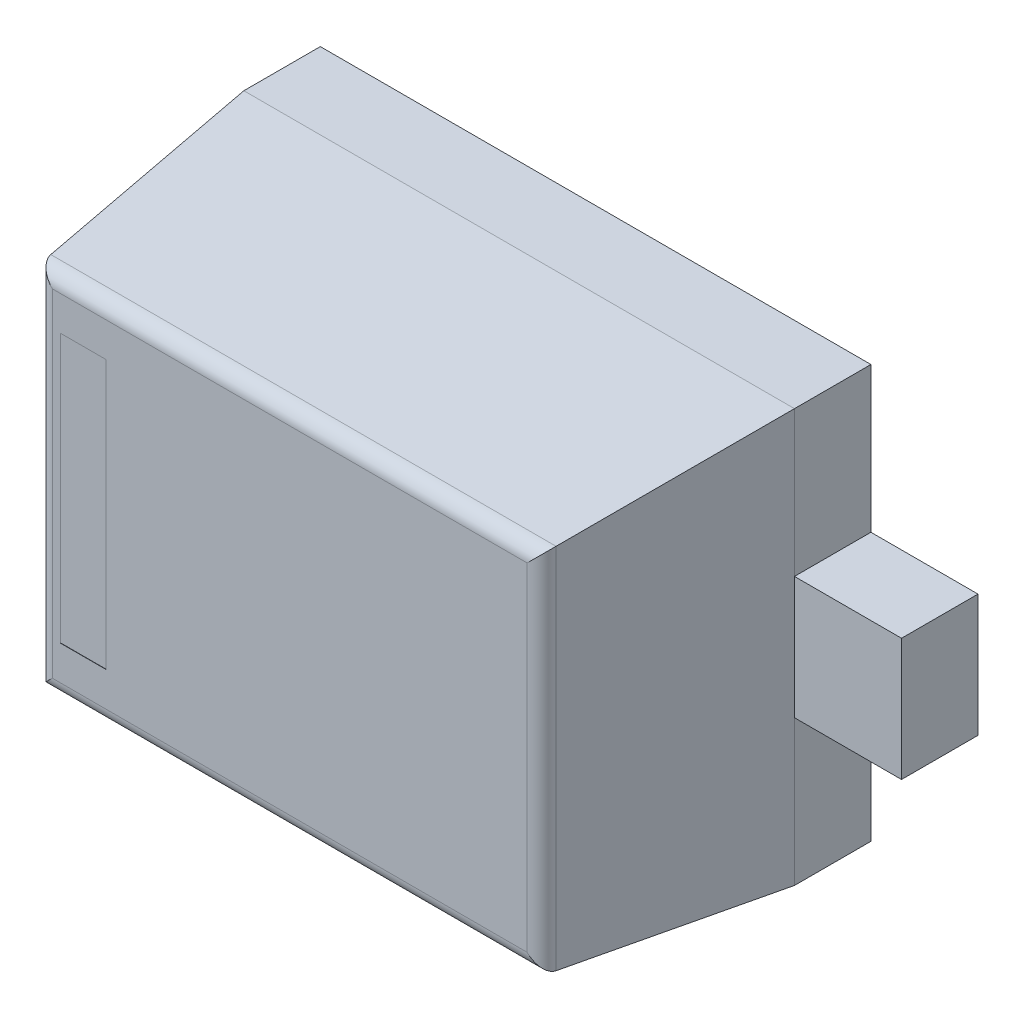
from build123d import *

# Parameters (mm, degrees)
SKBODY_W              = 1.8
SKBODY_H              = 1.35
BOSS_BODY_DEPTH       = 1
CHAMFER1_SIZE         = 0.75
CHAMFER1_SIZE2        = 0.078828176
CHAMFER1_PART_2_SIZE  = 0.75
CHAMFER1_PART_2_SIZE2 = 0.078828176
CHAMFER1_PART_3_SIZE  = 0.75
CHAMFER1_PART_3_SIZE2 = 0.078828176
CHAMFER1_PART_4_SIZE  = 0.75
CHAMFER1_PART_4_SIZE2 = 0.078828176
FILLET1_R             = 0.05
SKPOLARITY_W          = 0.15
SKPOLARITY_H          = 0.8775
CUT_PMARK_DEPTH       = 0.001
SKLEADS_W             = 0.35
SKLEADS_H             = 0.4
BOSS_LEADS_DEPTH      = 0.25


with BuildPart() as part:
    # SkBody → Boss-Body (new body)
    with BuildSketch(Plane.XY):
        Rectangle(SKBODY_W, SKBODY_H)
    extrude(amount=BOSS_BODY_DEPTH)

    # Chamfer1
    chamfer1_edges = [part.edges().sort_by_distance(p)[0] for p in [
        (-0.9, 0, 1),
    ]]
    chamfer1_side = [part.faces().sort_by_distance(p)[0] for p in [
        (-0.9, 0, 0.5),
    ]]
    chamfer(chamfer1_edges, length=CHAMFER1_SIZE, length2=CHAMFER1_SIZE2, reference=chamfer1_side[0])

    # Chamfer1 part 2
    chamfer1_part_2_edges = [part.edges().sort_by_distance(p)[0] for p in [
        (0, -0.675, 1),
    ]]
    chamfer1_part_2_side = [part.faces().sort_by_distance(p)[0] for p in [
        (0, -0.675, 0.5),
    ]]
    chamfer(chamfer1_part_2_edges, length=CHAMFER1_PART_2_SIZE, length2=CHAMFER1_PART_2_SIZE2, reference=chamfer1_part_2_side[0])

    # Chamfer1 part 3
    chamfer1_part_3_edges = [part.edges().sort_by_distance(p)[0] for p in [
        (0.9, 0, 1),
    ]]
    chamfer1_part_3_side = [part.faces().sort_by_distance(p)[0] for p in [
        (0.9, 0, 0.5),
    ]]
    chamfer(chamfer1_part_3_edges, length=CHAMFER1_PART_3_SIZE, length2=CHAMFER1_PART_3_SIZE2, reference=chamfer1_part_3_side[0])

    # Chamfer1 part 4
    chamfer1_part_4_edges = [part.edges().sort_by_distance(p)[0] for p in [
        (0, 0.675, 1),
    ]]
    chamfer1_part_4_side = [part.faces().sort_by_distance(p)[0] for p in [
        (0, 0.675, 0.5),
    ]]
    chamfer(chamfer1_part_4_edges, length=CHAMFER1_PART_4_SIZE, length2=CHAMFER1_PART_4_SIZE2, reference=chamfer1_part_4_side[0])

    # Fillet1
    fillet1_edges = [part.edges().sort_by_distance(p)[0] for p in [
        (0.821171824, 0, 1),
        (0, 0.596171824, 1),
        (-0.821171824, 0, 1),
        (0, -0.596171824, 1),
    ]]
    fillet(fillet1_edges, radius=FILLET1_R)

    # SkPolarity → Cut-PMark (cut)
    with BuildSketch(Plane.XY.offset(1)):
        with Locations((-0.675, 0)):
            Rectangle(SKPOLARITY_W, SKPOLARITY_H)
    extrude(amount=-CUT_PMARK_DEPTH, mode=Mode.SUBTRACT)

    # SkLeads → Boss-Leads (add)
    with BuildSketch(Plane.XY):
        with Locations((1.075, 0)):
            Rectangle(SKLEADS_W, SKLEADS_H)
        with Locations((-1.075, 0)):
            Rectangle(SKLEADS_W, SKLEADS_H)
    extrude(amount=BOSS_LEADS_DEPTH)


solid = part.part
